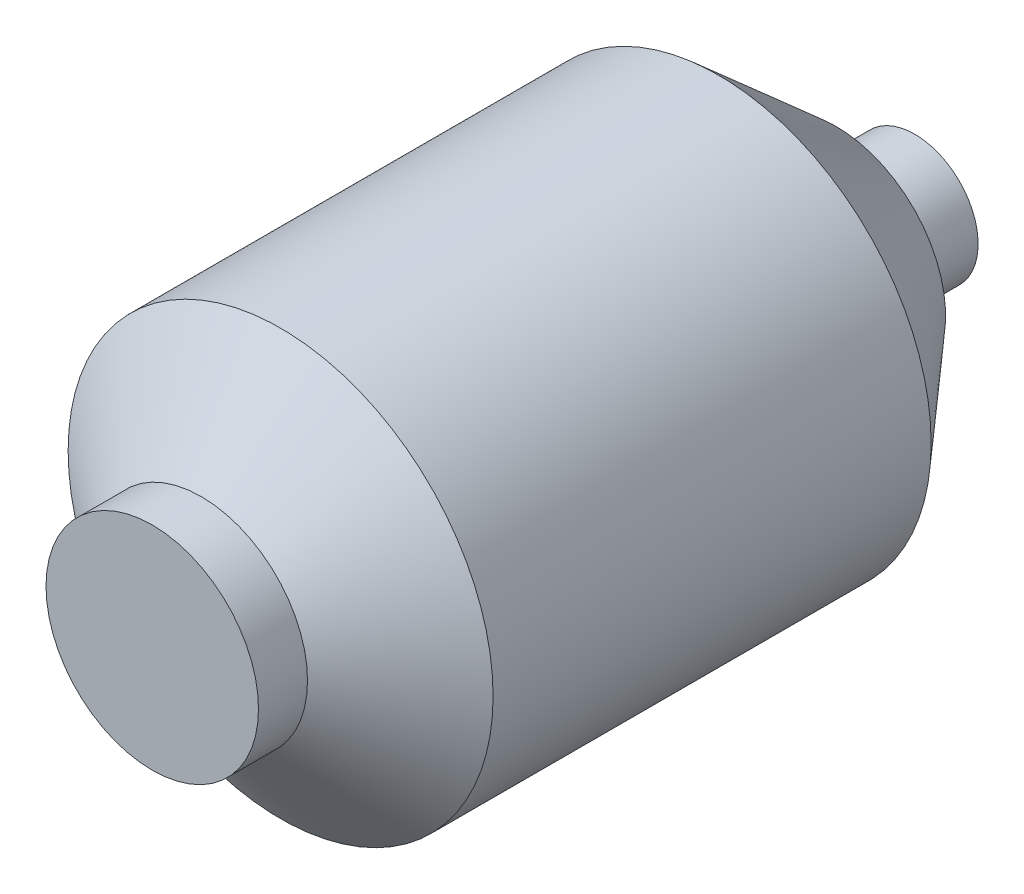
from build123d import *


with BuildPart() as part:
    # Sketch1 → Revolve1 (revolve)
    with BuildSketch(Plane(origin=(0, 0, 0), x_dir=(1, 0, 0), z_dir=(0, 1, 0))):
        Polygon((-33.481929622, 44.050922019), (-65, 8.116883117), (-65, -125.883116883), (-32.5, -150.153116883), (-32.5, -165.153116883), (0, -165.153116883), (0, -150.153116883), (0, 68.116883117), (-19.373457578, 68.116883117), (-19.373457578, 46.846883117), align=None)
    revolve(axis=Axis((0, 0, -73.083687066), (0, 0, 1)))


solid = part.part
